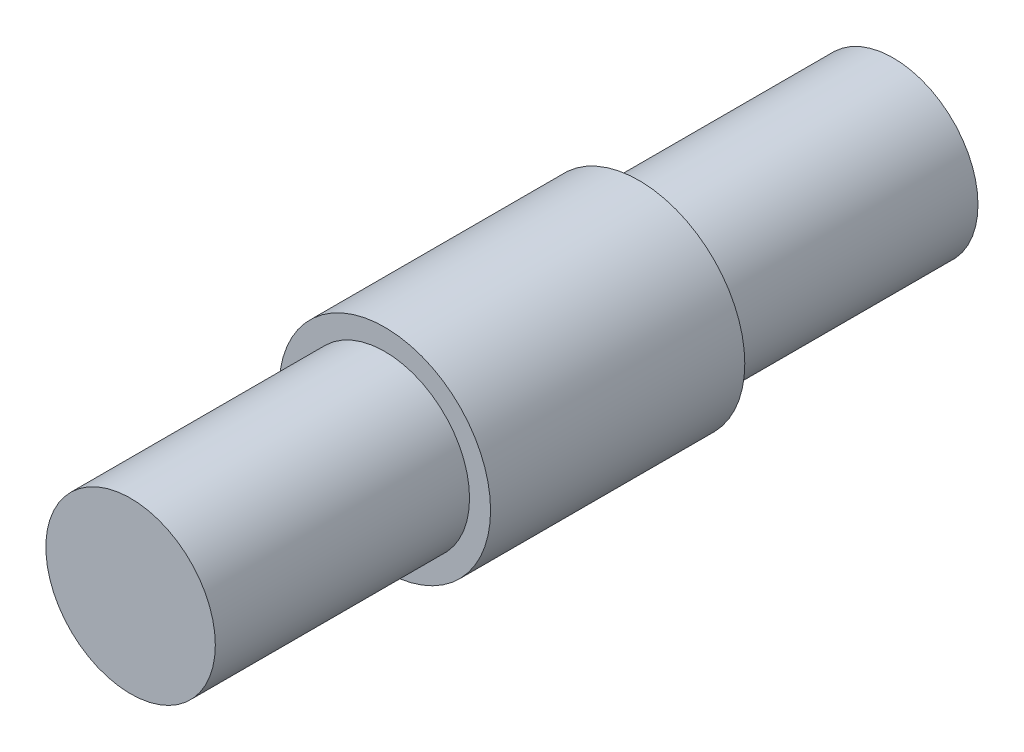
from build123d import *

# Parameters (mm, degrees)
SKETCH1_R           = 3.9624
BOSS_EXTRUDE1_DEPTH = 4.7625
SKETCH2_R           = 3.175
BOSS_EXTRUDE2_DEPTH = 14.2875


with BuildPart() as part:
    # Sketch1 → Boss-Extrude1 (new body, symmetric)
    with BuildSketch(Plane.XY):
        Circle(SKETCH1_R)
    extrude(amount=BOSS_EXTRUDE1_DEPTH, both=True)

    # Sketch2 → Boss-Extrude2 (add, symmetric)
    with BuildSketch(Plane.XY):
        Circle(SKETCH2_R)
    extrude(amount=BOSS_EXTRUDE2_DEPTH, both=True)


solid = part.part
